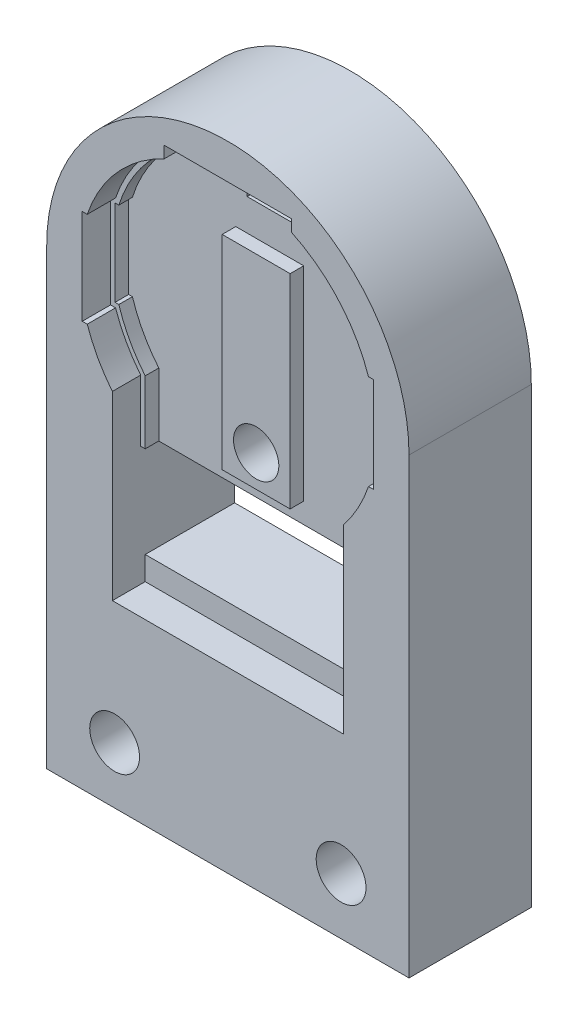
from build123d import *

# Parameters (mm, degrees)
BOSS_EXTRUDE1_DEPTH     = 1.5875
SKETCH3_W               = 3.81
SKETCH3_H               = 11.43
BOSS_EXTRUDE2_DEPTH     = 0.762
SKETCH4_W               = 12.954
SKETCH4_H               = 1.3208
BOSS_EXTRUDE3_DEPTH     = 0.508
SKETCH5_W               = 12.954
SKETCH5_H               = 5.3848
BOSS_EXTRUDE4_DEPTH     = 4.5085
SKETCH2_R               = 1.27
CUT_EXTRUDE1_DEPTH      = 20.612110439
CUT_EXTRUDE1_DEPTH_BACK = 20.612110439
CUT_EXTRUDE2_DEPTH      = 1.905
SKETCH7_W               = 20.32
SKETCH7_H               = 6.9342
BOSS_EXTRUDE5_DEPTH     = 6.858
SKETCH8_R               = 1.397
CUT_EXTRUDE3_DEPTH      = 24.146480805
SKETCH9_W               = 2.54
SKETCH9_H               = 1.27
CUT_EXTRUDE4_DEPTH      = 24.146480805


with BuildPart() as part:
    # Sketch1 → Boss-Extrude1 (new body)
    with BuildSketch(Plane.XY):
        with BuildLine():
            Line((-10.16, 5.7658), (-10.16, -12.7))
            Line((-10.16, -12.7), (10.16, -12.7))
            Line((10.16, -12.7), (10.16, 5.7658))
            ThreePointArc((10.16, 5.7658), (0, 15.9258), (-10.16, 5.7658))
        make_face()
        with BuildLine():
            Line((-8.1661, 8.4328), (-8.1661, 3.0988))
            Line((-8.1661, 3.0988), (-7.88607878, 3.0988))
            ThreePointArc((-7.88607878, 3.0988), (-7.294970241, 1.754997498), (-6.477, 0.535924426))
            Line((-6.477, 0.535924426), (-6.477, -9.624254818))
            Line((-6.477, -9.624254818), (6.477, -9.624254818))
            Line((6.477, -9.624254818), (6.477, 0.535924426))
            ThreePointArc((6.477, 0.535924426), (7.294970241, 1.754997498), (7.88607878, 3.0988))
            Line((7.88607878, 3.0988), (8.1661, 3.0988))
            Line((8.1661, 3.0988), (8.1661, 8.4328))
            Line((8.1661, 8.4328), (7.88607878, 8.4328))
            ThreePointArc((7.88607878, 8.4328), (6.220422148, 11.298383105), (3.5687, 13.286937403))
            Line((3.5687, 13.286937403), (3.5687, 13.946945182))
            Line((3.5687, 13.946945182), (-3.5687, 13.946945182))
            Line((-3.5687, 13.946945182), (-3.5687, 13.286937403))
            ThreePointArc((-3.5687, 13.286937403), (-6.220422148, 11.298383105), (-7.88607878, 8.4328))
            Line((-7.88607878, 8.4328), (-8.1661, 8.4328))
        make_face(mode=Mode.SUBTRACT)
    extrude(amount=BOSS_EXTRUDE1_DEPTH)

    # Sketch3 → Boss-Extrude2 (add)
    with BuildSketch(Plane(origin=(0, 0, 0), x_dir=(-1, 0, 0), z_dir=(0, 0, -1))):
        with BuildLine():
            Line((-10.16, -12.7), (10.16, -12.7))
            Line((10.16, -12.7), (10.16, 5.7658))
            ThreePointArc((10.16, 5.7658), (0, 15.9258), (-10.16, 5.7658))
            Line((-10.16, 5.7658), (-10.16, -12.7))
        make_face()
        with BuildLine():
            Line((-6.477, -9.624254818), (-6.477, -2.918654818))
            Line((-6.477, -2.918654818), (-6.223, -2.918654818))
            Line((-6.223, -2.918654818), (-6.223, 0.535924426))
            Line((-6.223, 0.535924426), (-6.223, 0.626452695))
            ThreePointArc((-6.223, 0.626452695), (-7.094540168, 1.917927921), (-7.70169142, 3.3528))
            Line((-7.70169142, 3.3528), (-7.9121, 3.3528))
            Line((-7.9121, 3.3528), (-7.9121, 8.1788))
            Line((-7.9121, 8.1788), (-7.70169142, 8.1788))
            ThreePointArc((-7.70169142, 8.1788), (-6.037827534, 11.121475344), (-3.3147, 13.124562371))
            Line((-3.3147, 13.124562371), (-3.3147, 13.692945182))
            Line((-3.3147, 13.692945182), (3.3147, 13.692945182))
            Line((3.3147, 13.692945182), (3.3147, 13.124562371))
            ThreePointArc((3.3147, 13.124562371), (6.037827534, 11.121475344), (7.70169142, 8.1788))
            Line((7.70169142, 8.1788), (7.9121, 8.1788))
            Line((7.9121, 8.1788), (7.9121, 3.3528))
            Line((7.9121, 3.3528), (7.70169142, 3.3528))
            ThreePointArc((7.70169142, 3.3528), (7.094540168, 1.917927921), (6.223, 0.626452695))
            Line((6.223, 0.626452695), (6.223, -2.918654818))
            Line((6.223, -2.918654818), (6.477, -2.918654818))
            Line((6.477, -2.918654818), (6.477, -9.624254818))
            Line((6.477, -9.624254818), (-6.223, -9.624254818))
            Line((-6.223, -9.624254818), (-6.477, -9.624254818))
        make_face(mode=Mode.SUBTRACT)
        with Locations((0, 3.939345182)):
            Rectangle(SKETCH3_W, SKETCH3_H)
    extrude(amount=BOSS_EXTRUDE2_DEPTH)


with BuildPart() as boss_extrude2_piece_1:
    # of the separate pieces the step leaves, piece 1, a body of its own (boss_extrude2_pieces)
    add(part.part.solids().sort_by_distance((-10.16, 5.7658, 1.5875))[0])

    # Sketch4 → Boss-Extrude3 (add)
    with BuildSketch(Plane(origin=(0, 0, -0.762), x_dir=(-1, 0, 0), z_dir=(0, 0, -1))):
        with Locations((0, -8.963854818)):
            Rectangle(SKETCH4_W, SKETCH4_H)
    extrude(amount=-BOSS_EXTRUDE3_DEPTH)



with BuildPart() as boss_extrude2_piece_2:
    # of the separate pieces the step leaves, piece 2, a body of its own (boss_extrude2_pieces)
    add(part.part.solids().sort_by_distance((-1.905, -1.775654818, 0))[0])


with BuildPart() as boss_extrude2_piece_1_1:
    add(boss_extrude2_piece_1.part)

    add(boss_extrude2_piece_2.part)  # Boss-Extrude4 merges Boss-Extrude2 piece 2
    # Sketch5 → Boss-Extrude4 (add)
    with BuildSketch(Plane(origin=(0, 0, -0.762), x_dir=(-1, 0, 0), z_dir=(0, 0, -1))):
        with BuildLine():
            Line((10.16, -12.7), (10.16, 5.7658))
            ThreePointArc((10.16, 5.7658), (0, 15.9258), (-10.16, 5.7658))
            Line((-10.16, 5.7658), (-10.16, -12.7))
            Line((-10.16, -12.7), (10.16, -12.7))
        make_face()
        with Locations((0, -5.611054818)):
            Rectangle(SKETCH5_W, SKETCH5_H, mode=Mode.SUBTRACT)
    extrude(amount=BOSS_EXTRUDE4_DEPTH)

    # Sketch2 → Cut-Extrude1 (cut, two sides)
    with BuildSketch(Plane.XY) as cut_extrude1_sk:
        Circle(SKETCH2_R)
    extrude(amount=CUT_EXTRUDE1_DEPTH, mode=Mode.SUBTRACT)
    extrude(cut_extrude1_sk.sketch, amount=-CUT_EXTRUDE1_DEPTH_BACK, mode=Mode.SUBTRACT)

    # Sketch6 → Cut-Extrude2 (cut)
    with BuildSketch(Plane(origin=(0, 0, -5.2705), x_dir=(-1, 0, 0), z_dir=(0, 0, -1))):
        Polygon((1.3931462, 2.413), (-1.3931462, 2.413), (-2.786292399, 0), (-1.3931462, -2.413), (1.3931462, -2.413), (2.786292399, 0), align=None)
    extrude(amount=-CUT_EXTRUDE2_DEPTH, mode=Mode.SUBTRACT)

    # Sketch7 → Boss-Extrude5 (add)
    with BuildSketch(Plane(origin=(0, 0, -5.2705), x_dir=(-1, 0, 0), z_dir=(0, 0, -1))):
        with Locations((0, -16.1671)):
            Rectangle(SKETCH7_W, SKETCH7_H)
    extrude(amount=-BOSS_EXTRUDE5_DEPTH)

    # Sketch8 → Cut-Extrude3 (cut, through all)
    with BuildSketch(Plane(origin=(0, 0, -5.2705), x_dir=(-1, 0, 0), z_dir=(0, 0, -1))):
        with Locations((-6.35, -16.4592)):
            Circle(SKETCH8_R)
        with Locations((6.35, -16.4592)):
            Circle(SKETCH8_R)
    extrude(amount=-CUT_EXTRUDE3_DEPTH, mode=Mode.SUBTRACT)

    # Sketch9 → Cut-Extrude4 (cut, through all)
    with BuildSketch(Plane(origin=(0, 0, -5.2705), x_dir=(-1, 0, 0), z_dir=(0, 0, -1))):
        with Locations((0, 12.065)):
            Rectangle(SKETCH9_W, SKETCH9_H)
    extrude(amount=-CUT_EXTRUDE4_DEPTH, mode=Mode.SUBTRACT)


solid = boss_extrude2_piece_1_1.part
